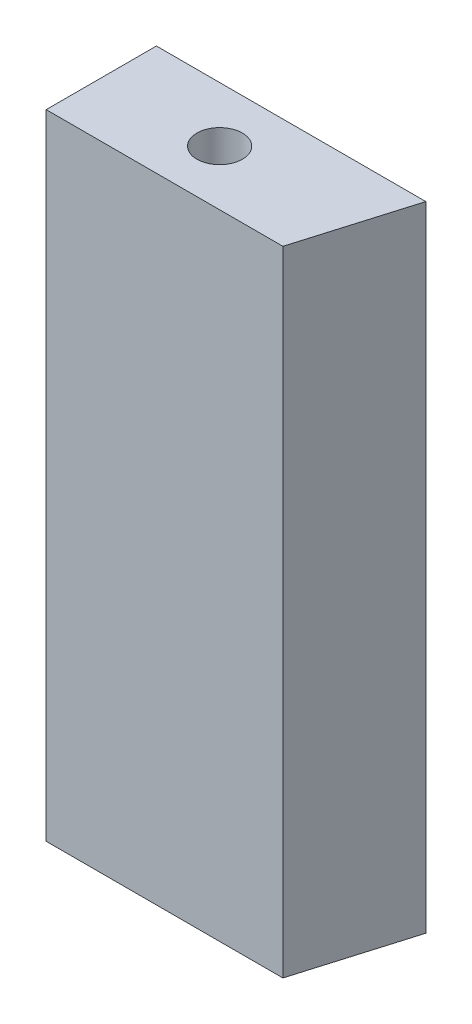
from build123d import *

# Parameters (mm, degrees)
BOSS_EXTRUDE1_DEPTH = 46
CUT_EXTRUDE1_REACH  = 48
SKETCH2_R           = 1.65
SKETCH3_R           = 1.65
CUT_EXTRUDE2_DEPTH  = 5


with BuildPart() as part:
    # Sketch1 → Boss-Extrude1 (new body)
    with BuildSketch(Plane(origin=(-73, 0, 0), x_dir=(0, 0, 1), z_dir=(0, 1, 0))):
        Polygon((82, 10.55666667), (90, 8.18333333), (90, -9), (82, -9), align=None)
    extrude(amount=BOSS_EXTRUDE1_DEPTH)

    # Sketch2 → Cut-Extrude1 (cut, up to next)
    with BuildSketch(Plane.XZ, mode=Mode.PRIVATE) as cut_extrude1_sk1:
        with Locations((-73.41, 86)):
            Circle(SKETCH2_R)
    cut_extrude1_tool1 = extrude(cut_extrude1_sk1.sketch, amount=-CUT_EXTRUDE1_REACH, mode=Mode.PRIVATE) & part.part
    add(cut_extrude1_tool1.solids().sort_by_distance((-73.41, 0, 86))[0], mode=Mode.SUBTRACT)

    # Sketch3 → Cut-Extrude2 (cut)
    with BuildSketch(Plane.ZY.offset(82)):
        with Locations((86, 34.5)):
            Circle(SKETCH3_R)
        with Locations((86, 11.5)):
            Circle(SKETCH3_R)
    extrude(amount=-CUT_EXTRUDE2_DEPTH, mode=Mode.SUBTRACT)


solid = part.part
